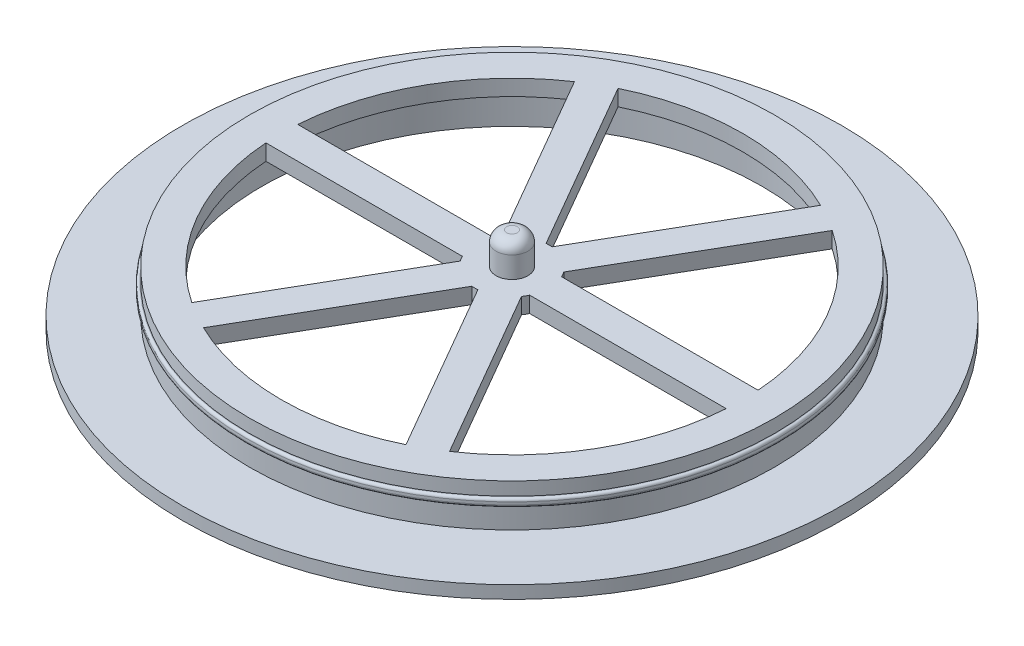
from build123d import *

# Parameters (mm, degrees)
SKETCH1_R           = 31
SKETCH1_R_2         = 23.5
BOSS_EXTRUDE1_DEPTH = 1.2
SKETCH2_R           = 24.7
SKETCH2_R_2         = 23.5
BOSS_EXTRUDE2_DEPTH = 4
BOSS_EXTRUDE3_START = -2
SKETCH3_R           = 25
SKETCH3_R_2         = 24.7
BOSS_EXTRUDE3_DEPTH = 0.75
FILLET1_R           = 0.25
BOSS_EXTRUDE4_DEPTH = 1.5
SKETCH5_R           = 24.7
SKETCH5_R_2         = 21.7
BOSS_EXTRUDE5_DEPTH = 1.5
SKETCH6_R           = 1.5
BOSS_EXTRUDE6_DEPTH = 3
FILLET2_R           = 1


with BuildPart() as part:
    # Sketch1 → Boss-Extrude1 (new body)
    with BuildSketch(Plane(origin=(0, 0, 0), x_dir=(1, 0, 0), z_dir=(0, 1, 0))):
        Circle(SKETCH1_R)
        Circle(SKETCH1_R_2, mode=Mode.SUBTRACT)
    extrude(amount=BOSS_EXTRUDE1_DEPTH)

    # Sketch2 → Boss-Extrude2 (add)
    with BuildSketch(Plane(origin=(0, 1.2, 0), x_dir=(1, 0, 0), z_dir=(0, 1, 0))):
        Circle(SKETCH2_R)
        Circle(SKETCH2_R_2, mode=Mode.SUBTRACT)
    extrude(amount=BOSS_EXTRUDE2_DEPTH)

    # Sketch3 → Boss-Extrude3 (add)
    with BuildSketch(Plane(origin=(0, 5.2, 0), x_dir=(1, 0, 0), z_dir=(0, 1, 0)).offset(BOSS_EXTRUDE3_START)):
        Circle(SKETCH3_R)
        Circle(SKETCH3_R_2, mode=Mode.SUBTRACT)
    extrude(amount=BOSS_EXTRUDE3_DEPTH)

    # Fillet1
    fillet1_edges = [part.edges().sort_by_distance(p)[0] for p in [
        (-25, 3.95, 0),
        (-25, 3.2, 0),
    ]]
    fillet(fillet1_edges, radius=FILLET1_R)

    # Sketch4 → Boss-Extrude4 (add)
    with BuildSketch(Plane(origin=(0, 5.2, 0), x_dir=(1, 0, 0), z_dir=(0, 1, 0))):
        with BuildLine():
            ThreePointArc((11.028167579, -22.101346562), (12.35, -21.390827473), (13.626243791, -20.601346562))
            Line((13.626243791, -20.601346562), (2.880176936, -1.988612788))
            ThreePointArc((2.880176936, -1.988612788), (3.031088913, -1.75), (3.16227766, -1.5))
            Line((3.16227766, -1.5), (24.65441137, -1.5))
            ThreePointArc((24.65441137, -1.5), (24.7, 0), (24.65441137, 1.5))
            Line((24.65441137, 1.5), (3.16227766, 1.5))
            ThreePointArc((3.16227766, 1.5), (3.030897524, 1.750331453), (2.879741939, 1.989242662))
            Line((2.879741939, 1.989242662), (13.625665835, 20.601728824))
            ThreePointArc((13.625665835, 20.601728824), (12.349399896, 21.391173932), (11.027547542, 22.101655938))
            Line((11.027547542, 22.101655938), (0.281337646, 3.488674409))
            ThreePointArc((0.281337646, 3.488674409), (-0.000382781, 3.499999979), (-0.282100724, 3.488612788))
            Line((-0.282100724, 3.488612788), (-11.028167579, 22.101346562))
            ThreePointArc((-11.028167579, 22.101346562), (-12.35, 21.390827473), (-13.626243791, 20.601346562))
            Line((-13.626243791, 20.601346562), (-2.880176936, 1.988612788))
            ThreePointArc((-2.880176936, 1.988612788), (-3.031088913, 1.75), (-3.16227766, 1.5))
            Line((-3.16227766, 1.5), (-24.65441137, 1.5))
            ThreePointArc((-24.65441137, 1.5), (-24.7, 0), (-24.65441137, -1.5))
            Line((-24.65441137, -1.5), (-3.16227766, -1.5))
            ThreePointArc((-3.16227766, -1.5), (-3.031280286, -1.749668491), (-2.88061184, -1.987982753))
            Line((-2.88061184, -1.987982753), (-13.626821737, -20.600964282))
            ThreePointArc((-13.626821737, -20.600964282), (-12.350600094, -21.390480998), (-11.028787606, -22.101037169))
            Line((-11.028787606, -22.101037169), (-0.28286371, -3.488551006))
            ThreePointArc((-0.28286371, -3.488551006), (-0.000382741, -3.499999979), (0.282100724, -3.488612788))
            Line((0.282100724, -3.488612788), (11.028167579, -22.101346562))
        make_face()
    extrude(amount=-BOSS_EXTRUDE4_DEPTH)

    # Sketch5 → Boss-Extrude5 (add)
    with BuildSketch(Plane(origin=(0, 5.2, 0), x_dir=(1, 0, 0), z_dir=(0, 1, 0))):
        Circle(SKETCH5_R)
        Circle(SKETCH5_R_2, mode=Mode.SUBTRACT)
    extrude(amount=-BOSS_EXTRUDE5_DEPTH)

    # Sketch6 → Boss-Extrude6 (add)
    with BuildSketch(Plane(origin=(0, 5.2, 0), x_dir=(1, 0, 0), z_dir=(0, 1, 0))):
        Circle(SKETCH6_R)
    extrude(amount=BOSS_EXTRUDE6_DEPTH)

    # Fillet2
    fillet2_edges = [part.edges().sort_by_distance(p)[0] for p in [
        (-1.5, 8.2, 0),
    ]]
    fillet(fillet2_edges, radius=FILLET2_R)


solid = part.part
